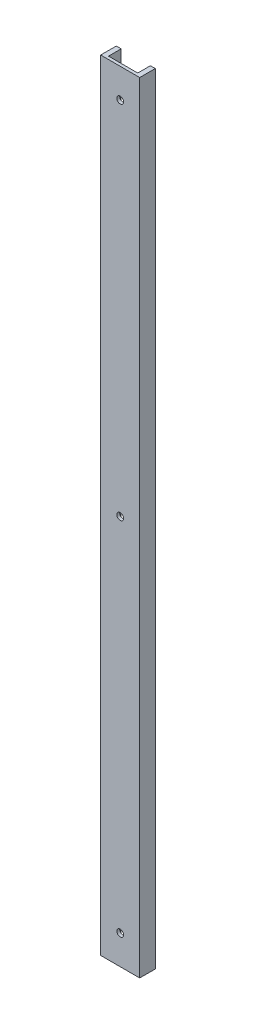
from build123d import *

# Parameters (mm, degrees)
SKETCH1_W           = 20
SKETCH1_H           = 8
BOSS_EXTRUDE1_DEPTH = 400
SKETCH2_W           = 15
SKETCH2_H           = 13
CUT_EXTRUDE1_DEPTH  = 401
SKETCH3_R           = 1.75
CUT_EXTRUDE2_DEPTH  = 2.5


with BuildPart() as part:
    # Sketch1 → Boss-Extrude1 (new body)
    with BuildSketch(Plane(origin=(0, 0, 0), x_dir=(1, 0, 0), z_dir=(0, 1, 0))):
        with Locations((10, 4)):
            Rectangle(SKETCH1_W, SKETCH1_H)
    extrude(amount=BOSS_EXTRUDE1_DEPTH)

    # Sketch2 → Cut-Extrude1 (cut, through all)
    with BuildSketch(Plane(origin=(0, 400, 0), x_dir=(1, 0, 0), z_dir=(0, 1, 0))):
        with Locations((10, 8)):
            Rectangle(SKETCH2_W, SKETCH2_H)
    extrude(amount=-CUT_EXTRUDE1_DEPTH, mode=Mode.SUBTRACT)

    # Sketch3 → Cut-Extrude2 (cut, through all)
    with BuildSketch(Plane(origin=(0, 0, -1.5), x_dir=(-1, 0, 0), z_dir=(0, 0, -1))):
        with Locations((-10, 385)):
            Circle(SKETCH3_R)
        with Locations((-10, 200)):
            Circle(SKETCH3_R)
        with Locations((-10, 15)):
            Circle(SKETCH3_R)
    extrude(amount=-CUT_EXTRUDE2_DEPTH, mode=Mode.SUBTRACT)


solid = part.part
